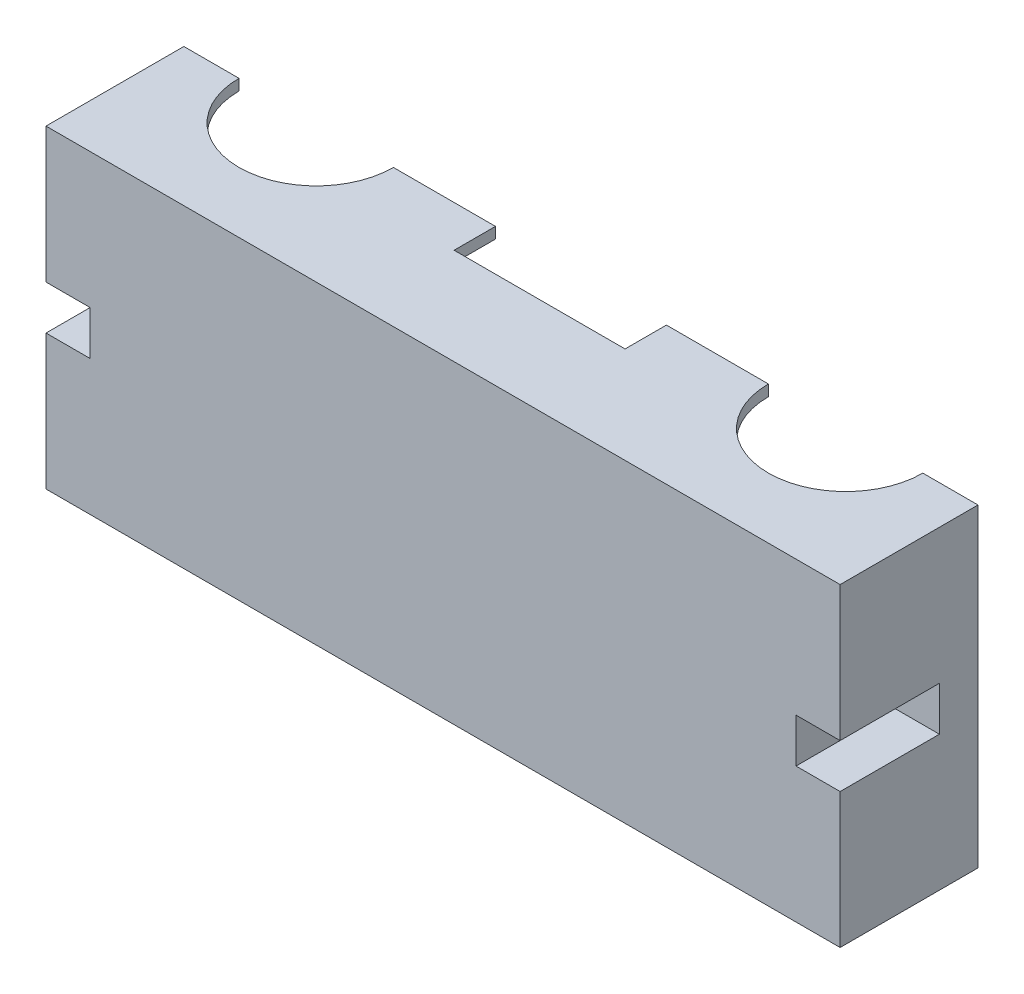
from build123d import *

# Parameters (mm, degrees)
SKIZZE1_W                       = 144
SKIZZE1_H                       = 57
AUFSATZ_LINEAR_AUSTRAGEN1_DEPTH = 25
SKIZZE2_W                       = 8
SKIZZE2_H                       = 8
SCHNITT_LINEAR_AUSTRAGEN4_DEPTH = 18
SKIZZE5_W                       = 140
SKIZZE5_H                       = 20
SKIZZE5_W_2                     = 125
SKIZZE5_H_2                     = 13
SCHNITT_LINEAR_AUSTRAGEN5_DEPTH = 23
SKIZZE6_R                       = 14
SKIZZE6_W                       = 31
SKIZZE6_H                       = 7.5
SCHNITT_LINEAR_AUSTRAGEN6_DEPTH = 2


with BuildPart() as part:
    # Skizze1 → Aufsatz-Linear austragen1 (new body)
    with BuildSketch(Plane.XY):
        with Locations((-30.959148289, 0.914772727)):
            Rectangle(SKIZZE1_W, SKIZZE1_H)
    extrude(amount=AUFSATZ_LINEAR_AUSTRAGEN1_DEPTH)

    # Skizze2 → Schnitt-Linear austragen4 (cut)
    with BuildSketch(Plane.XY.offset(25)):
        with Locations((37.040851711, 0.914772727)):
            Rectangle(SKIZZE2_W, SKIZZE2_H)
        with Locations((-98.959148289, 0.914772727)):
            Rectangle(SKIZZE2_W, SKIZZE2_H)
    extrude(amount=-SCHNITT_LINEAR_AUSTRAGEN4_DEPTH, mode=Mode.SUBTRACT)

    # Skizze5 → Schnitt-Linear austragen5 (cut)
    with BuildSketch(Plane(origin=(0, 0, 0), x_dir=(-1, 0, 0), z_dir=(0, 0, -1))):
        with Locations((30.959148289, 17.414772727)):
            Rectangle(SKIZZE5_W, SKIZZE5_H)
        with Locations((30.959148289, 0.914772727)):
            Rectangle(SKIZZE5_W_2, SKIZZE5_H_2)
        with Locations((30.959148289, -15.585227273)):
            Rectangle(SKIZZE5_W, SKIZZE5_H)
    extrude(amount=-SCHNITT_LINEAR_AUSTRAGEN5_DEPTH, mode=Mode.SUBTRACT)

    # Skizze6 → Schnitt-Linear austragen6 (cut)
    with BuildSketch(Plane(origin=(0, 29.414772727, 0), x_dir=(1, 0, 0), z_dir=(0, 1, 0))):
        with Locations((17.040851711, 0)):
            Circle(SKIZZE6_R)
        with Locations((-78.959148289, 0)):
            Circle(SKIZZE6_R)
        with Locations((-30.959148289, -3.75)):
            Rectangle(SKIZZE6_W, SKIZZE6_H)
    extrude(amount=-SCHNITT_LINEAR_AUSTRAGEN6_DEPTH, mode=Mode.SUBTRACT)


solid = part.part
